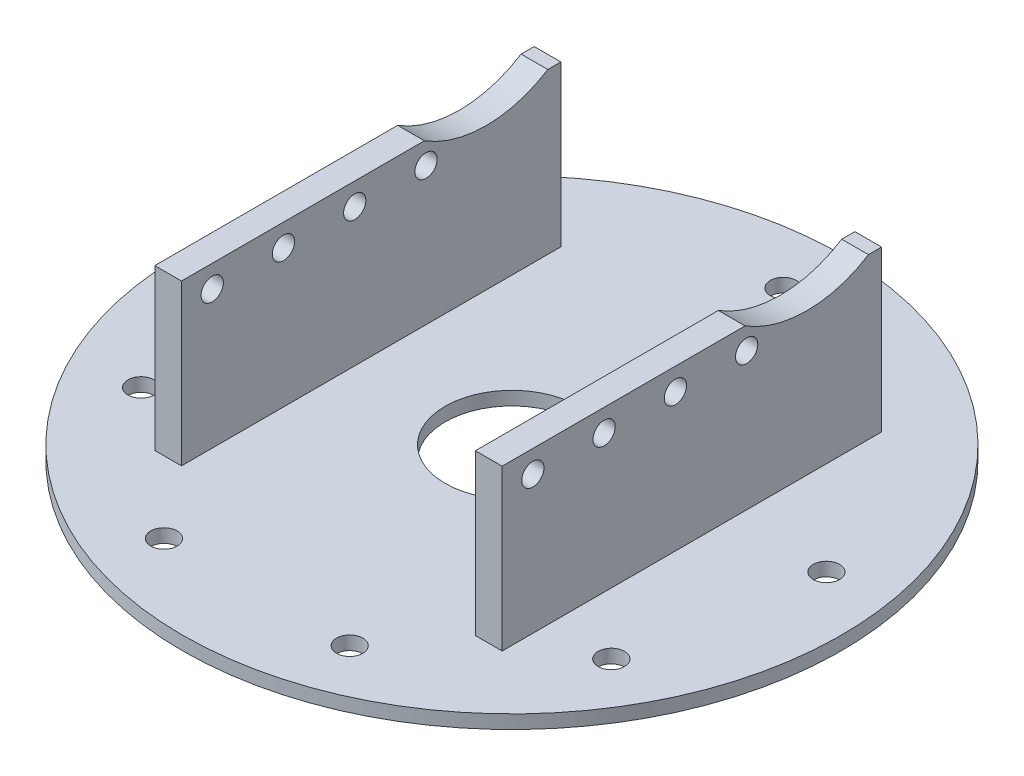
from build123d import *

# Parameters (mm, degrees)
IZIM1_W                          = 37
IZIM1_H                          = 1.524
IZIM2_W                          = 3
IZIM2_H                          = 42.6
Y_KSEKLIK_EKSTR_ZYON1_DEPTH      = 16.276
IZIM3_W                          = 3
IZIM3_H                          = 42.6
Y_KSEKLIK_EKSTR_ZYON2_DEPTH      = 16.276
DELIK1_D                         = 2.95656
DELIK1_DEPTH                     = 1.524
F_0_15_0_15_DIAMETER_HOLE1_D     = 15
F_0_15_0_15_DIAMETER_HOLE1_DEPTH = 17.8
IZIM15_W                         = 33
IZIM15_H                         = 48.693516851
KES_EKSTR_ZYON2_DEPTH            = 16.276
IZIM16_W                         = 42.6
IZIM16_H                         = 16.276
Y_KSEKLIK_EKSTR_ZYON3_DEPTH      = 1.5
IZIM17_W                         = 42.6
IZIM17_H                         = 16.276
Y_KSEKLIK_EKSTR_ZYON4_DEPTH      = 1.5
IZIM18_W                         = 42.6
IZIM18_H                         = 1.7
Y_KSEKLIK_EKSTR_ZYON5_DEPTH      = 3
IZIM19_W                         = 42.6
IZIM19_H                         = 1.7
Y_KSEKLIK_EKSTR_ZYON6_DEPTH      = 3
IZIM20_R                         = 13
KES_EKSTR_ZYON3_DEPTH            = 39
IZIM21_R                         = 1.25
KES_EKSTR_ZYON4_DEPTH            = 39


with BuildPart() as part:
    # Çizim1 → Döndür1 (revolve)
    with BuildSketch(Plane(origin=(0, 0, 0), x_dir=(-1, 0, 0), z_dir=(0, 0, -1))):
        with Locations((-18.5, 0.762)):
            Rectangle(IZIM1_W, IZIM1_H)
    revolve(axis=Axis((0, 0, 0), (0, 1, 0)))

    # Çizim2 → Yükseklik-Ekstrüzyon1 (add)
    with BuildSketch(Plane(origin=(0, 1.524, 0), x_dir=(-1, 0, 0), z_dir=(0, 1, 0))):
        with Locations((16.5, -0.7)):
            Rectangle(IZIM2_W, IZIM2_H)
    extrude(amount=Y_KSEKLIK_EKSTR_ZYON1_DEPTH)

    # Çizim3 → Yükseklik-Ekstrüzyon2 (add)
    with BuildSketch(Plane(origin=(0, 1.524, 0), x_dir=(-1, 0, 0), z_dir=(0, 1, 0))):
        with Locations((-16.5, -0.7)):
            Rectangle(IZIM3_W, IZIM3_H)
    extrude(amount=Y_KSEKLIK_EKSTR_ZYON2_DEPTH)

    # Delik1
    with Locations(Plane(origin=(0, 1.524, 0), x_dir=(1, 0, 0), z_dir=(0, 1, 0))):
        with Locations((0, 30.48), (30.016940312, 5.292796455), (26.396454307, -15.24), (10.424773969, -28.641831082), (-10.424773969, -28.641831082), (-26.396454307, -15.24), (-30.016940312, 5.292796455)):
            Hole(DELIK1_D / 2, depth=DELIK1_DEPTH)

    # Ø0.15 (0.15) Diameter Hole1
    with Locations(Plane(origin=(0, 0, 0), x_dir=(-1, 0, 0), z_dir=(0, -1, 0))):
        with Locations((0, 0)):
            Hole(F_0_15_0_15_DIAMETER_HOLE1_D / 2, depth=F_0_15_0_15_DIAMETER_HOLE1_DEPTH)

    # Çizim15 → Kes-Ekstrüzyon2 (cut)
    with BuildSketch(Plane(origin=(0, 17.8, 0), x_dir=(1, 0, 0), z_dir=(0, 1, 0))):
        with Locations((0, 0.128603458)):
            Rectangle(IZIM15_W, IZIM15_H)
    extrude(amount=-KES_EKSTR_ZYON2_DEPTH, mode=Mode.SUBTRACT)

    # Çizim16 → Yükseklik-Ekstrüzyon3 (add)
    with BuildSketch(Plane(origin=(18, 0, 0), x_dir=(0, 0, -1), z_dir=(1, 0, 0))):
        with Locations((0.7, 9.662)):
            Rectangle(IZIM16_W, IZIM16_H)
    extrude(amount=Y_KSEKLIK_EKSTR_ZYON3_DEPTH)

    # Çizim17 → Yükseklik-Ekstrüzyon4 (add)
    with BuildSketch(Plane.ZY.offset(18)):
        with Locations((-0.7, 9.662)):
            Rectangle(IZIM17_W, IZIM17_H)
    extrude(amount=Y_KSEKLIK_EKSTR_ZYON4_DEPTH)

    # Çizim18 → Yükseklik-Ekstrüzyon5 (add)
    with BuildSketch(Plane.ZY.offset(19.5)):
        with Locations((-0.7, 18.65)):
            Rectangle(IZIM18_W, IZIM18_H)
    extrude(amount=-Y_KSEKLIK_EKSTR_ZYON5_DEPTH)

    # Çizim19 → Yükseklik-Ekstrüzyon6 (add)
    with BuildSketch(Plane(origin=(19.5, 0, 0), x_dir=(0, 0, -1), z_dir=(1, 0, 0))):
        with Locations((0.7, 18.65)):
            Rectangle(IZIM19_W, IZIM19_H)
    extrude(amount=-Y_KSEKLIK_EKSTR_ZYON6_DEPTH)

    # Çizim20 → Kes-Ekstrüzyon3 (cut)
    with BuildSketch(Plane.ZY.offset(19.5)):
        with Locations((-13.6, 30.5)):
            Circle(IZIM20_R)
    extrude(amount=-KES_EKSTR_ZYON3_DEPTH, mode=Mode.SUBTRACT)

    # Çizim21 → Kes-Ekstrüzyon4 (cut)
    with BuildSketch(Plane.ZY.offset(19.5)):
        with Locations((17.15, 17)):
            Circle(IZIM21_R)
        with Locations((9.15, 17)):
            Circle(IZIM21_R)
        with Locations((1.15, 17)):
            Circle(IZIM21_R)
        with Locations((-6.85, 17)):
            Circle(IZIM21_R)
    extrude(amount=-KES_EKSTR_ZYON4_DEPTH, mode=Mode.SUBTRACT)


solid = part.part
